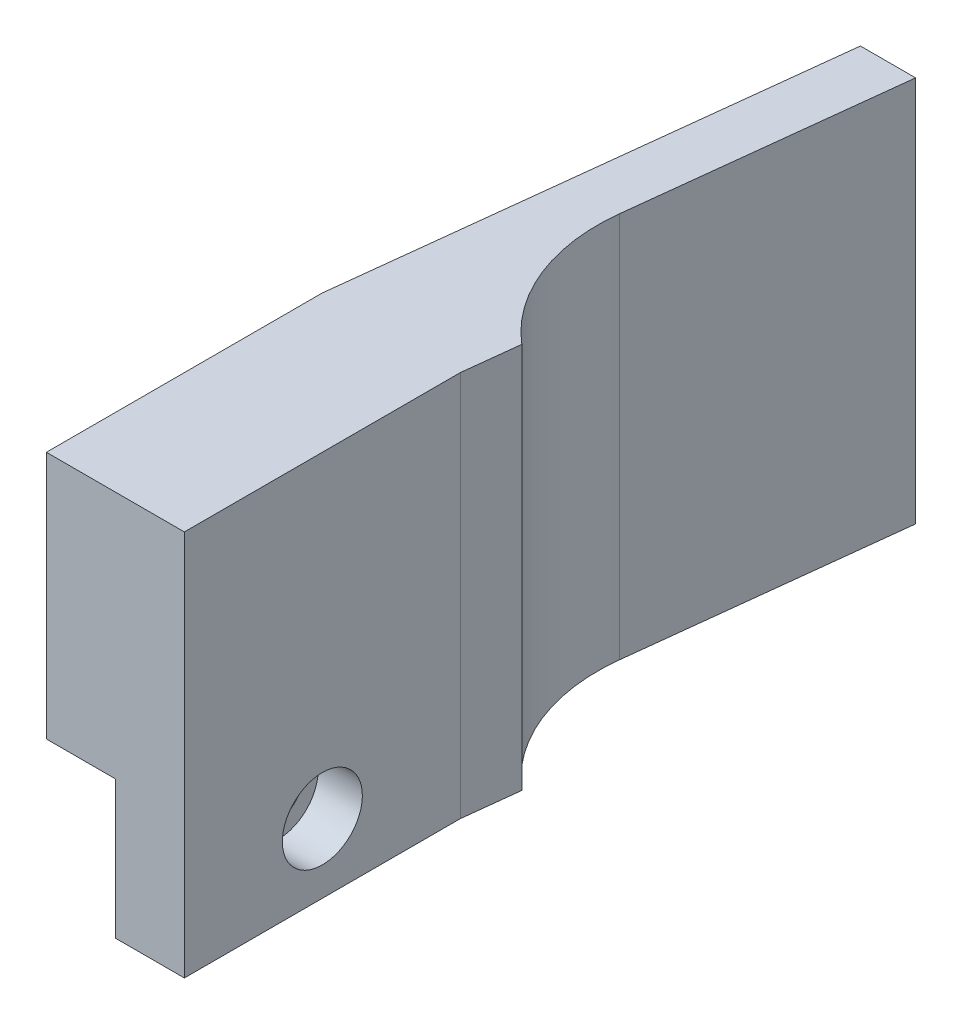
from build123d import *

# Parameters (mm, degrees)
PROFILE_W               = 12.7
PROFILE_H               = 22.86
PROFILE_W_2             = 6.35
PROFILE_H_2             = 12.7
BOSS_EXTRUDE1_DEPTH     = 12.7
SCREWHOLE_R             = 2.159
CUT_EXTRUDE1_DEPTH      = 7.35
CUT_EXTRUDE1_DEPTH_BACK = 7.35
SKETCH3_R               = 3.683
SKETCH3_R_2             = 2.159
CUT_EXTRUDE2_DEPTH      = 4.064
BOSS_EXTRUDE2_DEPTH     = 35.56


with BuildPart() as part:
    # Profile → Boss-Extrude1 (new body, symmetric)
    with BuildSketch(Plane.XY):
        with Locations((0, 11.43)):
            Rectangle(PROFILE_W, PROFILE_H)
        with Locations((3.175, -6.35)):
            Rectangle(PROFILE_W_2, PROFILE_H_2)
    extrude(amount=BOSS_EXTRUDE1_DEPTH, both=True)

    # ScrewHole → Cut-Extrude1 (cut, two sides)
    with BuildSketch(Plane.ZY) as cut_extrude1_sk:
        with Locations((0, -6.35)):
            Circle(SCREWHOLE_R)
    extrude(amount=CUT_EXTRUDE1_DEPTH, mode=Mode.SUBTRACT)
    extrude(cut_extrude1_sk.sketch, amount=-CUT_EXTRUDE1_DEPTH_BACK, mode=Mode.SUBTRACT)

    # Sketch3 → Cut-Extrude2 (cut)
    with BuildSketch(Plane(origin=(6.35, 0, 0), x_dir=(0, 0, -1), z_dir=(1, 0, 0))):
        with Locations((0, -6.35)):
            Circle(SKETCH3_R)
        with Locations((0, -6.35)):
            Circle(SKETCH3_R_2, mode=Mode.SUBTRACT)
    extrude(amount=-CUT_EXTRUDE2_DEPTH, mode=Mode.SUBTRACT)

    # Sketch5 → Boss-Extrude2 (add)
    with BuildSketch(Plane.XZ.offset(12.7)):
        with BuildLine():
            Line((-1.27, -57.15), (3.81, -57.15))
            Line((3.81, -57.15), (1.016473553, -32.70664359))
            ThreePointArc((1.016473553, -32.70664359), (2.103447964, -24.502378011), (6.930571429, -17.78))
            Line((6.930571429, -17.78), (6.35, -12.7))
            Line((6.35, -12.7), (0, -12.7))
            Line((0, -12.7), (-6.35, -12.7))
            Line((-6.35, -12.7), (-1.27, -57.15))
        make_face()
    extrude(amount=-BOSS_EXTRUDE2_DEPTH)


solid = part.part
